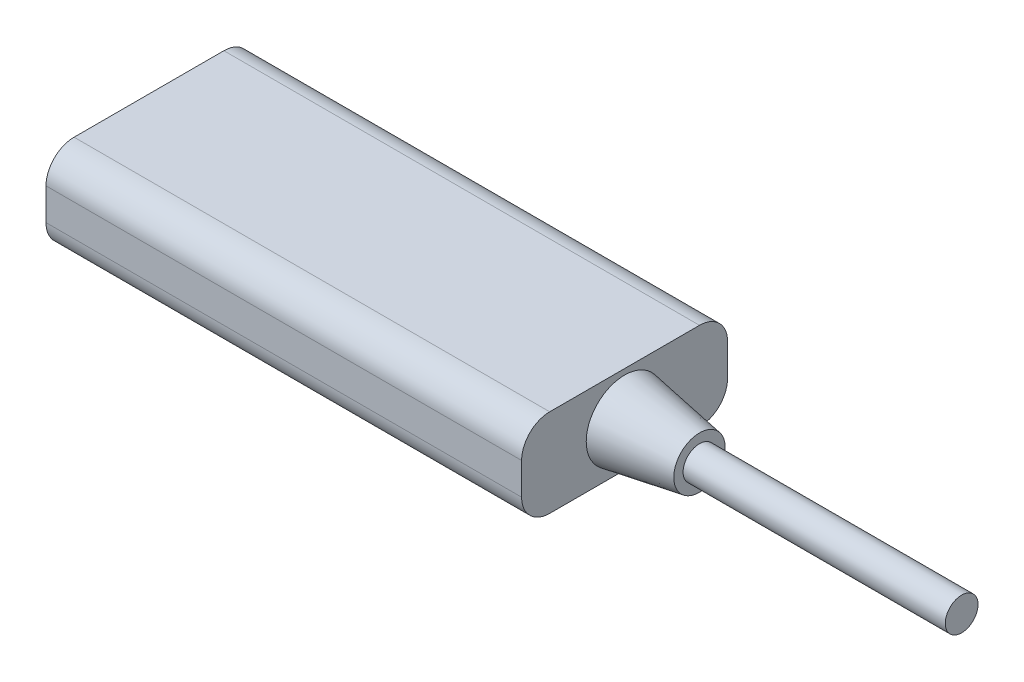
from build123d import *

# Parameters (mm, degrees)
SKETCH_1_W          = 22
SKETCH_1_H          = 9.4
EXTRUDE_1_DEPTH     = 50.8
FILLET_1_R          = 3
SKETCH_4_R          = 1.65
CUT_EXTRUDE_1_DEPTH = 10


with BuildPart() as part:
    # Эскиз1 → Бобышка-Вытянуть1 (new body)
    with BuildSketch(Plane(origin=(0, 0, 0), x_dir=(0, 0, -1), z_dir=(1, 0, 0))):
        Rectangle(SKETCH_1_W, SKETCH_1_H)
    extrude(amount=-EXTRUDE_1_DEPTH)

    # Эскиз3 → Повернуть1 (revolve)
    with BuildSketch(Plane(origin=(0, 0, 0), x_dir=(1, 0, 0), z_dir=(0, 1, 0))):
        Polygon((8, 2.75), (0, 4.1), (0, 0), (36, 0), (36, 1.75), (8, 1.75), align=None)
    revolve(axis=Axis((0, 0, 0), (1, 0, 0)))

    # Скругление1
    fillet_1_edges = [part.edges().sort_by_distance(p)[0] for p in [
        (-25.4, -4.7, 11),
        (-25.4, 4.7, 11),
        (-25.4, 4.7, -11),
        (-25.4, -4.7, -11),
    ]]
    fillet(fillet_1_edges, radius=FILLET_1_R)

    # Эскиз4 → Вырез-Вытянуть1 (cut)
    with BuildSketch(Plane.ZY.offset(50.8)):
        with Locations((-4.4, 0.6)):
            Circle(SKETCH_4_R)
        with Locations((4.4, 0.6)):
            Circle(SKETCH_4_R)
    extrude(amount=-CUT_EXTRUDE_1_DEPTH, mode=Mode.SUBTRACT)


solid = part.part
